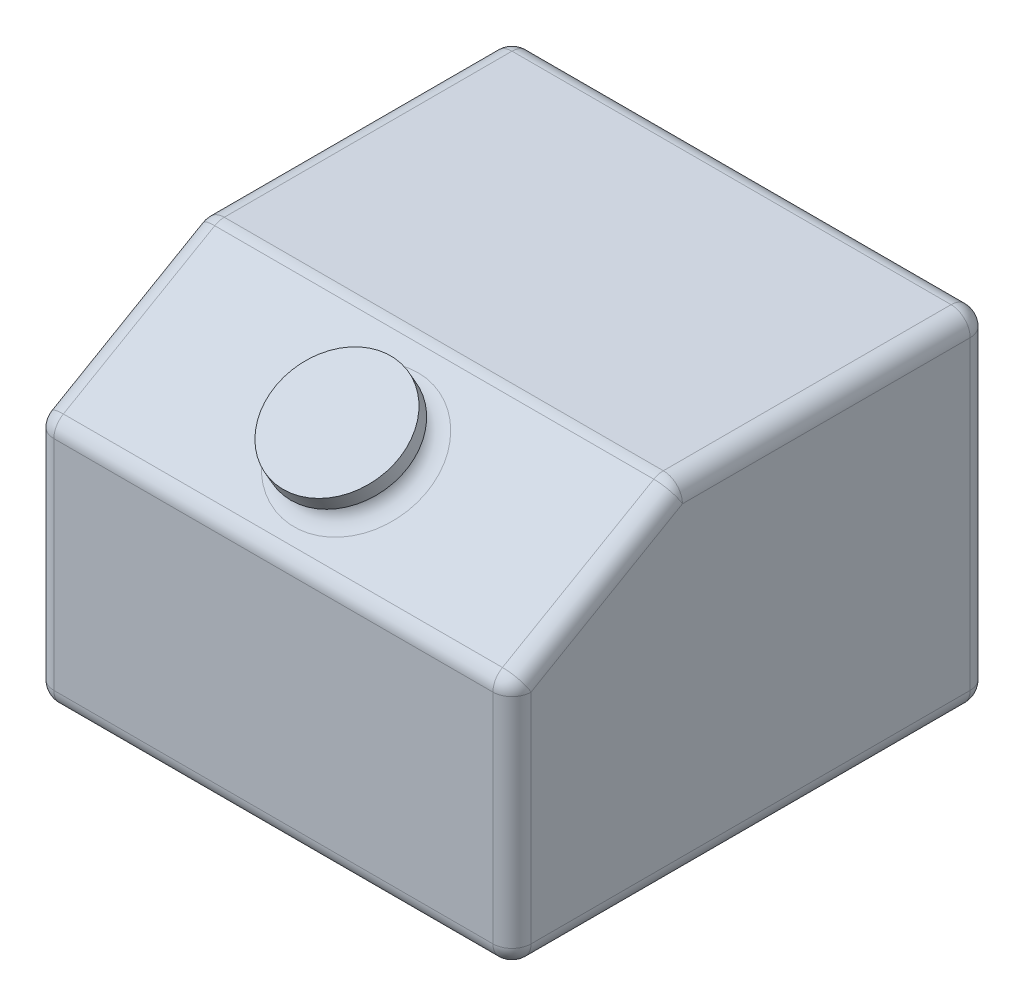
from build123d import *

# Parameters (mm, degrees)
SKETCH_1_W          = 250
SKETCH_1_H          = 250
EXTRUDE_1_DEPTH     = 180
CHAMFER_1_SIZE      = 50
CHAMFER_1_SIZE2     = 86.602540378
SKETCH_2_R          = 27.5
EXTRUDE_2_DEPTH     = 20
EXTRUDE_START       = 12
SKETCH_2_3_R        = 32.5
SKETCH_2_3_R_2      = 27.5
EXTRUDE_3_DEPTH     = 8
FILLET_1_R          = 10
CUT_EXTRUDE_START   = -10
CUT_EXTRUDE_1_DEPTH = 230


with BuildPart() as part:
    # 스케치1 → 보스-돌출1 (new body)
    with BuildSketch(Plane(origin=(0, 0, 0), x_dir=(1, 0, 0), z_dir=(0, 1, 0))):
        with Locations((125, 125)):
            Rectangle(SKETCH_1_W, SKETCH_1_H)
    extrude(amount=EXTRUDE_1_DEPTH)

    # 모따기1
    chamfer_1_edges = [part.edges().sort_by_distance(p)[0] for p in [
        (125, 180, 0),
    ]]
    chamfer_1_side = [part.faces().sort_by_distance(p)[0] for p in [
        (125, 90, 0),
    ]]
    chamfer(chamfer_1_edges, length=CHAMFER_1_SIZE, length2=CHAMFER_1_SIZE2, reference=chamfer_1_side[0])

    # 스케치2 → 보스-돌출2 (add)
    with BuildSketch(Plane(origin=(0, 97.5, 56.291651246), x_dir=(1, 0, 0), z_dir=(0, 0.8660254037844379, 0.5000000000000014))):
        with Locations((125, 115)):
            Circle(SKETCH_2_R)
    extrude(amount=EXTRUDE_2_DEPTH)

    # 스케치2<3> → 보스-돌출3 (add)
    with BuildSketch(Plane(origin=(0, 97.5, 56.291651246), x_dir=(1, 0, 0), z_dir=(0, 0.8660254037844379, 0.5000000000000014)).offset(EXTRUDE_START)):
        with Locations((125, 115)):
            Circle(SKETCH_2_3_R)
        with Locations((125, 115)):
            Circle(SKETCH_2_3_R_2, mode=Mode.SUBTRACT)
    extrude(amount=EXTRUDE_3_DEPTH)

    # 필렛1
    fillet_1_edges = [part.edges().sort_by_distance(p)[0] for p in [
        (97.5, 155, -43.301270189),
        (125, 180, -86.602540378),
        (0, 180, -168.301270189),
        (0, 155, -43.301270189),
        (125, 180, -250),
        (0, 90, -250),
        (250, 90, -250),
        (250, 155, -43.301270189),
        (250, 180, -168.301270189),
        (0, 65, 0),
        (125, 130, 0),
        (250, 65, 0),
        (125, 0, 0),
        (250, 0, -125),
        (125, 0, -250),
        (0, 0, -125),
    ]]
    fillet(fillet_1_edges, radius=FILLET_1_R)

    # 스케치3 → 컷-돌출1 (cut)
    with BuildSketch(Plane(origin=(250, 0, 0), x_dir=(0, 0, -1), z_dir=(1, 0, 0)).offset(CUT_EXTRUDE_START)):
        Polygon((237, 13), (237, 167), (90.08587988, 167), (13, 122.494446501), (13, 13), align=None)
    extrude(amount=-CUT_EXTRUDE_1_DEPTH, mode=Mode.SUBTRACT)


solid = part.part
